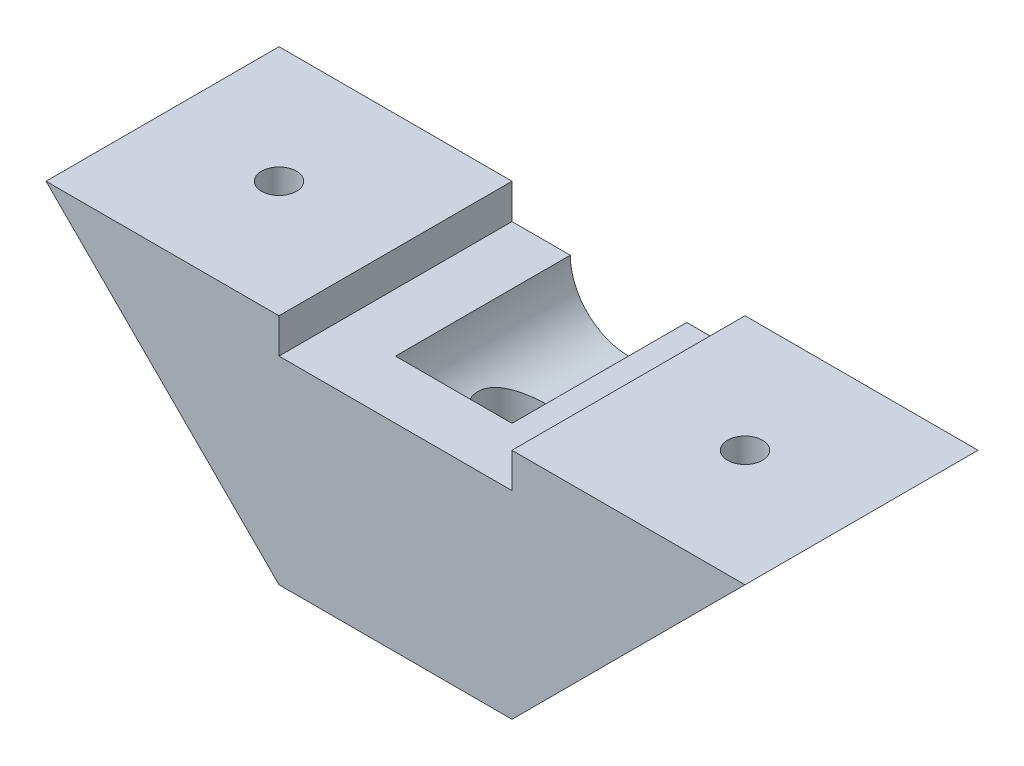
from build123d import *

# Parameters (mm, degrees)
BOSS_EXTRU_1_DEPTH      = 15
BOSS_EXTRU_2_DEPTH      = 5
ENL_V_MAT_EXTRU_1_DEPTH = 20
ESQUISSE4_R             = 2.9
ESQUISSE4_R_2           = 1.6
ENL_V_MAT_EXTRU_2_DEPTH = 12
ENL_V_MAT_EXTRU_3_DEPTH = 12
ESQUISSE7_R             = 1.5
ENL_V_MAT_EXTRU_5_DEPTH = 15


with BuildPart() as part:
    # Esquisse1 → Boss.-Extru.1 (new body)
    with BuildSketch(Plane.XY):
        Polygon((0, 20), (20, 0), (20, 20), align=None)
        with BuildLine():
            Line((20, 17), (20, 0))
            Line((20, 0), (40, 0))
            Line((40, 0), (40, 17))
            Line((40, 17), (35, 17))
            ThreePointArc((35, 17), (30, 12), (25, 17))
            Line((25, 17), (20, 17))
        make_face()
        Polygon((40, 0), (40, 20), (60, 20), align=None)
    extrude(amount=BOSS_EXTRU_1_DEPTH)

    # Esquisse3 → Boss.-Extru.2 (add)
    with BuildSketch(Plane.XY.offset(15)):
        with BuildLine():
            Line((25, 17), (35, 17))
            ThreePointArc((35, 17), (30, 12), (25, 17))
        make_face()
        with BuildLine():
            Line((20, 20), (0, 20))
            Line((0, 20), (20, 0))
            Line((20, 0), (40, 0))
            Line((40, 0), (60, 20))
            Line((60, 20), (40, 20))
            Line((40, 20), (40, 17))
            Line((40, 17), (35, 17))
            ThreePointArc((35, 17), (30, 12), (25, 17))
            Line((25, 17), (20, 17))
            Line((20, 17), (20, 20))
        make_face()
    extrude(amount=BOSS_EXTRU_2_DEPTH)

    # Esquisse2 → Enlèv. mat.-Extru.1 (cut)
    with BuildSketch(Plane(origin=(0, 20, 0), x_dir=(1, 0, 0), z_dir=(0, 1, 0))):
        with BuildLine():
            ThreePointArc((31.6, -10), (31.13137085, -8.86862915), (30, -8.4))
            Line((30, -8.4), (30, -10))
            Line((30, -10), (31.6, -10))
        make_face()
        with BuildLine():
            Line((30, -10), (30, -8.4))
            ThreePointArc((30, -8.4), (28.86862915, -11.13137085), (31.6, -10))
            Line((31.6, -10), (30, -10))
        make_face()
    extrude(amount=-ENL_V_MAT_EXTRU_1_DEPTH, mode=Mode.SUBTRACT)

    # Esquisse4 → Enlèv. mat.-Extru.2 (cut)
    with BuildSketch(Plane(origin=(0, 20, 0), x_dir=(1, 0, 0), z_dir=(0, 1, 0))):
        with Locations((30, -10)):
            Circle(ESQUISSE4_R)
        with Locations((30, -10)):
            Circle(ESQUISSE4_R_2, mode=Mode.SUBTRACT)
    extrude(amount=-ENL_V_MAT_EXTRU_2_DEPTH, mode=Mode.SUBTRACT)

    # Esquisse5 → Enlèv. mat.-Extru.3 (cut)
    with BuildSketch(Plane(origin=(0, 20, 0), x_dir=(1, 0, 0), z_dir=(0, 1, 0))):
        with BuildLine():
            ThreePointArc((51.5, -10), (51.385819299, -9.425974851), (51.060660172, -8.939339828))
            Line((51.060660172, -8.939339828), (50, -10))
            Line((50, -10), (51.060660172, -11.060660172))
            ThreePointArc((51.060660172, -11.060660172), (51.385819299, -10.574025149), (51.5, -10))
        make_face()
        with BuildLine():
            Line((50, -10), (51.060660172, -8.939339828))
            ThreePointArc((51.060660172, -8.939339828), (50, -8.5), (48.939339828, -8.939339828))
            Line((48.939339828, -8.939339828), (50, -10))
        make_face()
        with BuildLine():
            Line((50, -10), (48.939339828, -8.939339828))
            ThreePointArc((48.939339828, -8.939339828), (48.5, -10), (48.939339828, -11.060660172))
            Line((48.939339828, -11.060660172), (50, -10))
        make_face()
        with BuildLine():
            ThreePointArc((48.939339828, -11.060660172), (50, -11.5), (51.060660172, -11.060660172))
            Line((51.060660172, -11.060660172), (50, -10))
            Line((50, -10), (48.939339828, -11.060660172))
        make_face()
        with BuildLine():
            ThreePointArc((11.5, -10), (11.385819299, -9.425974851), (11.060660172, -8.939339828))
            Line((11.060660172, -8.939339828), (10, -10))
            Line((10, -10), (11.060660172, -11.060660172))
            ThreePointArc((11.060660172, -11.060660172), (11.385819299, -10.574025149), (11.5, -10))
        make_face()
        with BuildLine():
            Line((10, -10), (11.060660172, -8.939339828))
            ThreePointArc((11.060660172, -8.939339828), (10, -8.5), (8.939339828, -8.939339828))
            Line((8.939339828, -8.939339828), (10, -10))
        make_face()
        with BuildLine():
            Line((10, -10), (8.939339828, -8.939339828))
            ThreePointArc((8.939339828, -8.939339828), (8.5, -10), (8.939339828, -11.060660172))
            Line((8.939339828, -11.060660172), (10, -10))
        make_face()
        with BuildLine():
            ThreePointArc((8.939339828, -11.060660172), (10, -11.5), (11.060660172, -11.060660172))
            Line((11.060660172, -11.060660172), (10, -10))
            Line((10, -10), (8.939339828, -11.060660172))
        make_face()
    extrude(amount=-ENL_V_MAT_EXTRU_3_DEPTH, mode=Mode.SUBTRACT)

    # Esquisse7 → Enlèv. mat.-Extru.5 (cut)
    with BuildSketch(Plane.XZ):
        Polygon((10, 6.882308546), (12.7, 8.441154273), (12.7, 11.558845727), (10, 13.117691454), (7.3, 11.558845727), (7.3, 8.441154273), align=None)
        with Locations((10, 10)):
            Circle(ESQUISSE7_R, mode=Mode.SUBTRACT)
        Polygon((50, 6.882308546), (52.7, 8.441154273), (52.7, 11.558845727), (50, 13.117691454), (47.3, 11.558845727), (47.3, 8.441154273), align=None)
        with Locations((50, 10)):
            Circle(ESQUISSE7_R, mode=Mode.SUBTRACT)
    extrude(amount=-ENL_V_MAT_EXTRU_5_DEPTH, mode=Mode.SUBTRACT)


solid = part.part
